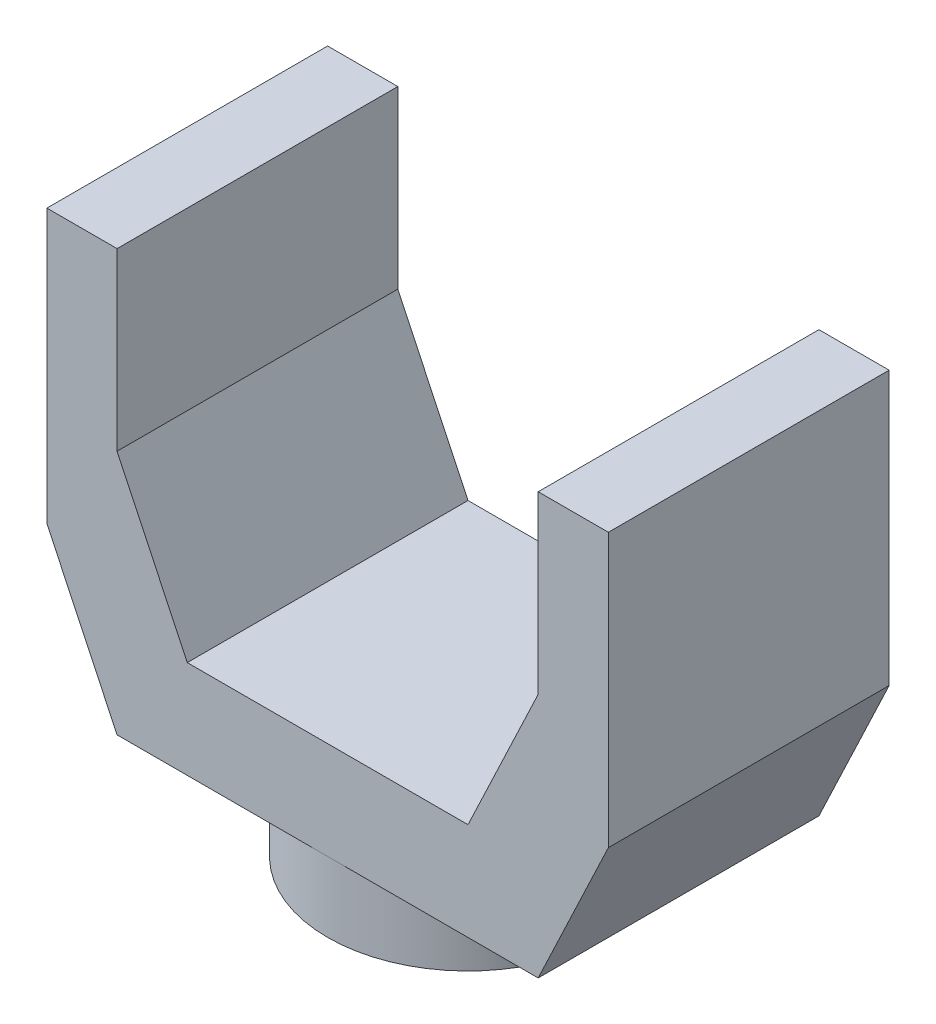
from build123d import *

# Parameters (mm, degrees)
BOSS_EXTRUDE1_DEPTH = 25.4
SKETCH2_R           = 25.4
BOSS_EXTRUDE2_DEPTH = 12.7


with BuildPart() as part:
    # Sketch1 → Boss-Extrude1 (new body, symmetric)
    with BuildSketch(Plane.XY):
        Polygon((-38.1, 0), (38.1, 0), (50.8, 26.773950856), (50.8, 76.2), (38.1, 76.2), (38.1, 44.45), (25.4, 17.676049144), (-25.4, 17.676049144), (-38.1, 44.45), (-38.1, 76.2), (-50.8, 76.2), (-50.8, 26.773950856), align=None)
    extrude(amount=BOSS_EXTRUDE1_DEPTH, both=True)

    # Sketch2 → Boss-Extrude2 (add)
    with BuildSketch(Plane.XZ):
        Circle(SKETCH2_R)
    extrude(amount=BOSS_EXTRUDE2_DEPTH)


solid = part.part
